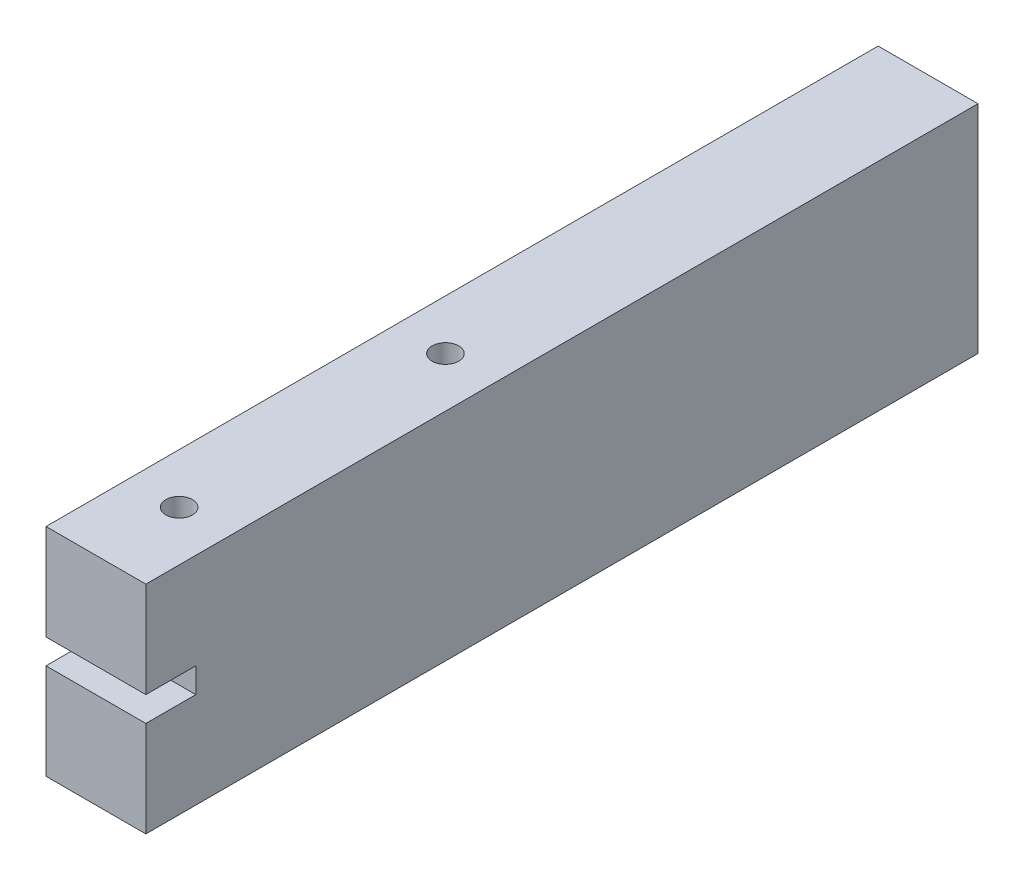
from build123d import *

# Parameters (mm, degrees)
SKETCH1_W          = 12
SKETCH1_H          = 100
SKETCH1_R          = 1.6
EXTRUDE1_DEPTH     = 13
SKETCH2_W          = 12
SKETCH2_H          = 6
CUT_EXTRUDE1_DEPTH = 1.5


with BuildPart() as part:
    # Sketch1 → Extrude1 (new body, symmetric)
    with BuildSketch(Plane(origin=(0, 0, 0), x_dir=(1, 0, 0), z_dir=(0, 1, 0))):
        with Locations((0, 50)):
            Rectangle(SKETCH1_W, SKETCH1_H)
        with Locations(Location((0, 10, 0), (0, 0, 270))):  # turned: the seam where the file's is
            Circle(SKETCH1_R, mode=Mode.SUBTRACT)
        with Locations(Location((0, 42, 0), (0, 0, 270))):  # turned: the seam where the file's is
            Circle(SKETCH1_R, mode=Mode.SUBTRACT)
    extrude(amount=EXTRUDE1_DEPTH, both=True)

    # Sketch2 → Cut-Extrude1 (cut, symmetric)
    with BuildSketch(Plane(origin=(0, 0, 0), x_dir=(1, 0, 0), z_dir=(0, 1, 0))):
        with Locations((0, 3)):
            Rectangle(SKETCH2_W, SKETCH2_H)
    extrude(amount=CUT_EXTRUDE1_DEPTH, both=True, mode=Mode.SUBTRACT)


solid = part.part
